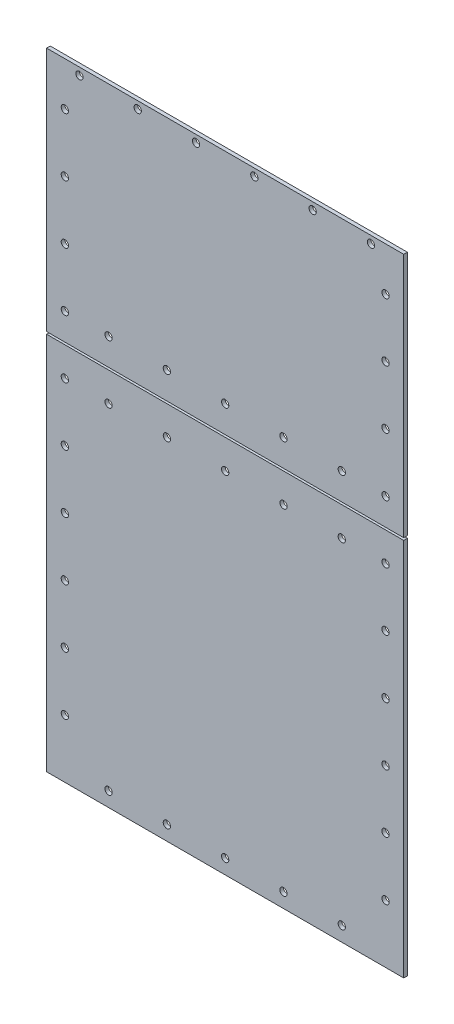
from build123d import *

# Parameters (mm, degrees)
SKETCH1_W             = 155.58
SKETCH1_H             = 106.95
SKETCH1_R             = 1.5875
BOSS_EXTRUDE1_DEPTH   = 1.5875
SKETCH1_H_2           = 165.1
BOSS_EXTRUDE1_2_DEPTH = 1.5875


with BuildPart() as part:
    # Sketch1 → Boss-Extrude1 (new body)
    with BuildSketch(Plane.XY):
        with Locations((77.79, -53.475)):
            Rectangle(SKETCH1_W, SKETCH1_H)
        with Locations((7.94, -95.25)):
            Circle(SKETCH1_R, mode=Mode.SUBTRACT)
        with Locations((7.94, -69.85)):
            Circle(SKETCH1_R, mode=Mode.SUBTRACT)
        with Locations((26.99, -95.25)):
            Circle(SKETCH1_R, mode=Mode.SUBTRACT)
        with Locations((52.39, -95.25)):
            Circle(SKETCH1_R, mode=Mode.SUBTRACT)
        with Locations((77.79, -95.25)):
            Circle(SKETCH1_R, mode=Mode.SUBTRACT)
        with Locations((7.94, -44.45)):
            Circle(SKETCH1_R, mode=Mode.SUBTRACT)
        with Locations((7.94, -19.05)):
            Circle(SKETCH1_R, mode=Mode.SUBTRACT)
        with Locations((14.29, -3.175)):
            Circle(SKETCH1_R, mode=Mode.SUBTRACT)
        with Locations((39.69, -3.175)):
            Circle(SKETCH1_R, mode=Mode.SUBTRACT)
        with Locations((65.09, -3.175)):
            Circle(SKETCH1_R, mode=Mode.SUBTRACT)
        with Locations((103.19, -95.25)):
            Circle(SKETCH1_R, mode=Mode.SUBTRACT)
        with Locations((128.59, -95.25)):
            Circle(SKETCH1_R, mode=Mode.SUBTRACT)
        with Locations((147.64, -95.25)):
            Circle(SKETCH1_R, mode=Mode.SUBTRACT)
        with Locations((147.64, -69.85)):
            Circle(SKETCH1_R, mode=Mode.SUBTRACT)
        with Locations((90.49, -3.175)):
            Circle(SKETCH1_R, mode=Mode.SUBTRACT)
        with Locations((115.89, -3.175)):
            Circle(SKETCH1_R, mode=Mode.SUBTRACT)
        with Locations((147.64, -44.45)):
            Circle(SKETCH1_R, mode=Mode.SUBTRACT)
        with Locations((147.64, -19.05)):
            Circle(SKETCH1_R, mode=Mode.SUBTRACT)
        with Locations((141.29, -3.175)):
            Circle(SKETCH1_R, mode=Mode.SUBTRACT)
    extrude(amount=BOSS_EXTRUDE1_DEPTH)


with BuildPart() as body_2:
    # Sketch1 → Boss-Extrude1 2 (new body)
    with BuildSketch(Plane.XY):
        with Locations((77.79, -190.5)):
            Rectangle(SKETCH1_W, SKETCH1_H_2)
        with Locations((7.94, -247.65)):
            Circle(SKETCH1_R, mode=Mode.SUBTRACT)
        with Locations((26.987, -266.7)):
            Circle(SKETCH1_R, mode=Mode.SUBTRACT)
        with Locations((7.94, -222.25)):
            Circle(SKETCH1_R, mode=Mode.SUBTRACT)
        with Locations((52.387, -266.7)):
            Circle(SKETCH1_R, mode=Mode.SUBTRACT)
        with Locations((77.787, -266.7)):
            Circle(SKETCH1_R, mode=Mode.SUBTRACT)
        with Locations((7.94, -196.85)):
            Circle(SKETCH1_R, mode=Mode.SUBTRACT)
        with Locations((7.94, -171.45)):
            Circle(SKETCH1_R, mode=Mode.SUBTRACT)
        with Locations((7.94, -146.05)):
            Circle(SKETCH1_R, mode=Mode.SUBTRACT)
        with Locations((103.187, -266.7)):
            Circle(SKETCH1_R, mode=Mode.SUBTRACT)
        with Locations((128.587, -266.7)):
            Circle(SKETCH1_R, mode=Mode.SUBTRACT)
        with Locations((147.64, -247.65)):
            Circle(SKETCH1_R, mode=Mode.SUBTRACT)
        with Locations((147.64, -222.25)):
            Circle(SKETCH1_R, mode=Mode.SUBTRACT)
        with Locations((147.64, -196.85)):
            Circle(SKETCH1_R, mode=Mode.SUBTRACT)
        with Locations((147.64, -171.45)):
            Circle(SKETCH1_R, mode=Mode.SUBTRACT)
        with Locations((147.64, -146.05)):
            Circle(SKETCH1_R, mode=Mode.SUBTRACT)
        with Locations((7.94, -120.65)):
            Circle(SKETCH1_R, mode=Mode.SUBTRACT)
        with Locations((26.99, -120.65)):
            Circle(SKETCH1_R, mode=Mode.SUBTRACT)
        with Locations((52.39, -120.65)):
            Circle(SKETCH1_R, mode=Mode.SUBTRACT)
        with Locations((77.79, -120.65)):
            Circle(SKETCH1_R, mode=Mode.SUBTRACT)
        with Locations((103.19, -120.65)):
            Circle(SKETCH1_R, mode=Mode.SUBTRACT)
        with Locations((128.59, -120.65)):
            Circle(SKETCH1_R, mode=Mode.SUBTRACT)
        with Locations((147.64, -120.65)):
            Circle(SKETCH1_R, mode=Mode.SUBTRACT)
    extrude(amount=BOSS_EXTRUDE1_2_DEPTH)


solid = Compound([part.part, body_2.part])
